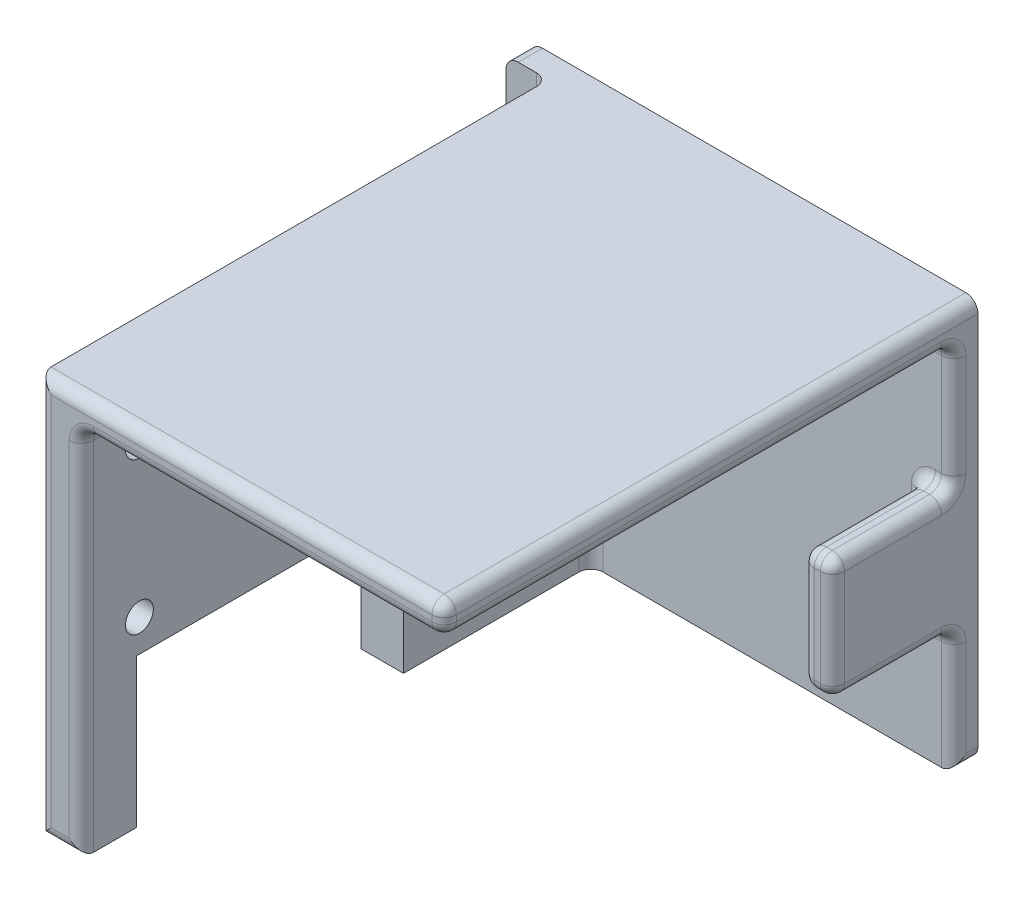
from build123d import *

# Parameters (mm, degrees)
SKETCH1_W           = 36.9
SKETCH1_H           = 32.9
SKETCH1_R           = 1.5
BOSS_EXTRUDE1_DEPTH = 2
BOSS_EXTRUDE2_DEPTH = 42
SKETCH5_W           = 2.5
SKETCH5_H           = 10
BOSS_EXTRUDE3_DEPTH = 10
FILLET1_R           = 1
CUT_EXTRUDE1_REACH  = 9
SKETCH3_R           = 1.15
SKETCH3_W           = 22
SKETCH3_H           = 12.25


with BuildPart() as part:
    # Sketch1 → Boss-Extrude1 (new body)
    with BuildSketch(Plane.XY):
        with Locations((18.45, 16.45)):
            Rectangle(SKETCH1_W, SKETCH1_H)
        with Locations((18.45, 16.45)):
            Circle(SKETCH1_R, mode=Mode.SUBTRACT)
    extrude(amount=BOSS_EXTRUDE1_DEPTH)

    # Sketch2 → Boss-Extrude2 (add)
    with BuildSketch(Plane.XY.offset(2)):
        Polygon((3.5, 0), (7, 0), (7, 30.4), (36.9, 30.4), (36.9, 32.9), (3.5, 32.9), align=None)
    extrude(amount=BOSS_EXTRUDE2_DEPTH)

    # Sketch5 → Boss-Extrude3 (add)
    with BuildSketch(Plane.XY.offset(2)):
        with Locations((35.65, 15)):
            Rectangle(SKETCH5_W, SKETCH5_H)
    extrude(amount=BOSS_EXTRUDE3_DEPTH)

    # Fillet1
    fillet1_edges = [part.edges().sort_by_distance(p)[0] for p in [
        (3.5, 16.45, 2),
        (7, 15.2, 2),
        (21.95, 30.4, 2),
        (7, 30.4, 23),
        (36.9, 30.4, 23),
        (3.5, 16.45, 44),
        (5.25, 0, 44),
        (7, 15.2, 44),
        (21.95, 30.4, 44),
        (36.9, 31.65, 44),
        (20.2, 32.9, 44),
        (36.9, 25.2, 2),
        (36.9, 10, 7),
        (35.65, 20, 2),
        (36.9, 20, 7),
        (34.4, 15, 2),
        (34.4, 20, 7),
        (35.65, 10, 2),
        (34.4, 10, 7),
        (36.9, 15, 12),
        (35.65, 20, 12),
        (34.4, 15, 12),
        (35.65, 10, 12),
        (36.9, 5, 2),
        (36.9, 0, 1),
        (0, 0, 1),
        (0, 32.9, 1),
        (36.9, 32.9, 22),
    ]]
    fillet(fillet1_edges, radius=FILLET1_R)

    # Sketch3 → Cut-Extrude1 (cut, up to next)
    with BuildSketch(Plane(origin=(7, 0, 0), x_dir=(0, 0, -1), z_dir=(1, 0, 0)), mode=Mode.PRIVATE) as cut_extrude1_sk1:
        with Locations((-39.215, 27.4)):
            Circle(SKETCH3_R)
    cut_extrude1_tool1 = extrude(cut_extrude1_sk1.sketch, amount=-CUT_EXTRUDE1_REACH, mode=Mode.PRIVATE) & part.part
    add(cut_extrude1_tool1.solids().sort_by_distance((7, 27.4, 39.215))[0], mode=Mode.SUBTRACT)
    # Sketch3 → Cut-Extrude1 (cut, up to next)
    with BuildSketch(Plane(origin=(7, 0, 0), x_dir=(0, 0, -1), z_dir=(1, 0, 0)), mode=Mode.PRIVATE) as cut_extrude1_sk2:
        with Locations((-17.685, 27.4)):
            Circle(SKETCH3_R)
    cut_extrude1_tool2 = extrude(cut_extrude1_sk2.sketch, amount=-CUT_EXTRUDE1_REACH, mode=Mode.PRIVATE) & part.part
    add(cut_extrude1_tool2.solids().sort_by_distance((7, 27.4, 17.685))[0], mode=Mode.SUBTRACT)
    # Sketch3 → Cut-Extrude1 (cut, up to next)
    with BuildSketch(Plane(origin=(7, 0, 0), x_dir=(0, 0, -1), z_dir=(1, 0, 0)), mode=Mode.PRIVATE) as cut_extrude1_sk3:
        with Locations((-39.215, 14.9)):
            Circle(SKETCH3_R)
    cut_extrude1_tool3 = extrude(cut_extrude1_sk3.sketch, amount=-CUT_EXTRUDE1_REACH, mode=Mode.PRIVATE) & part.part
    add(cut_extrude1_tool3.solids().sort_by_distance((7, 14.9, 39.215))[0], mode=Mode.SUBTRACT)
    # Sketch3 → Cut-Extrude1 (cut, up to next)
    with BuildSketch(Plane(origin=(7, 0, 0), x_dir=(0, 0, -1), z_dir=(1, 0, 0)), mode=Mode.PRIVATE) as cut_extrude1_sk4:
        with Locations((-17.685, 14.9)):
            Circle(SKETCH3_R)
    cut_extrude1_tool4 = extrude(cut_extrude1_sk4.sketch, amount=-CUT_EXTRUDE1_REACH, mode=Mode.PRIVATE) & part.part
    add(cut_extrude1_tool4.solids().sort_by_distance((7, 14.9, 17.685))[0], mode=Mode.SUBTRACT)
    # Sketch3 → Cut-Extrude1 (cut, up to next)
    with BuildSketch(Plane(origin=(7, 0, 0), x_dir=(0, 0, -1), z_dir=(1, 0, 0)), mode=Mode.PRIVATE) as cut_extrude1_sk5:
        with Locations((-28.45, 6.125)):
            Rectangle(SKETCH3_W, SKETCH3_H)
    cut_extrude1_tool5 = extrude(cut_extrude1_sk5.sketch, amount=-CUT_EXTRUDE1_REACH, mode=Mode.PRIVATE) & part.part
    add(cut_extrude1_tool5.solids().sort_by_distance((7, 6.125, 28.45))[0], mode=Mode.SUBTRACT)


solid = part.part
